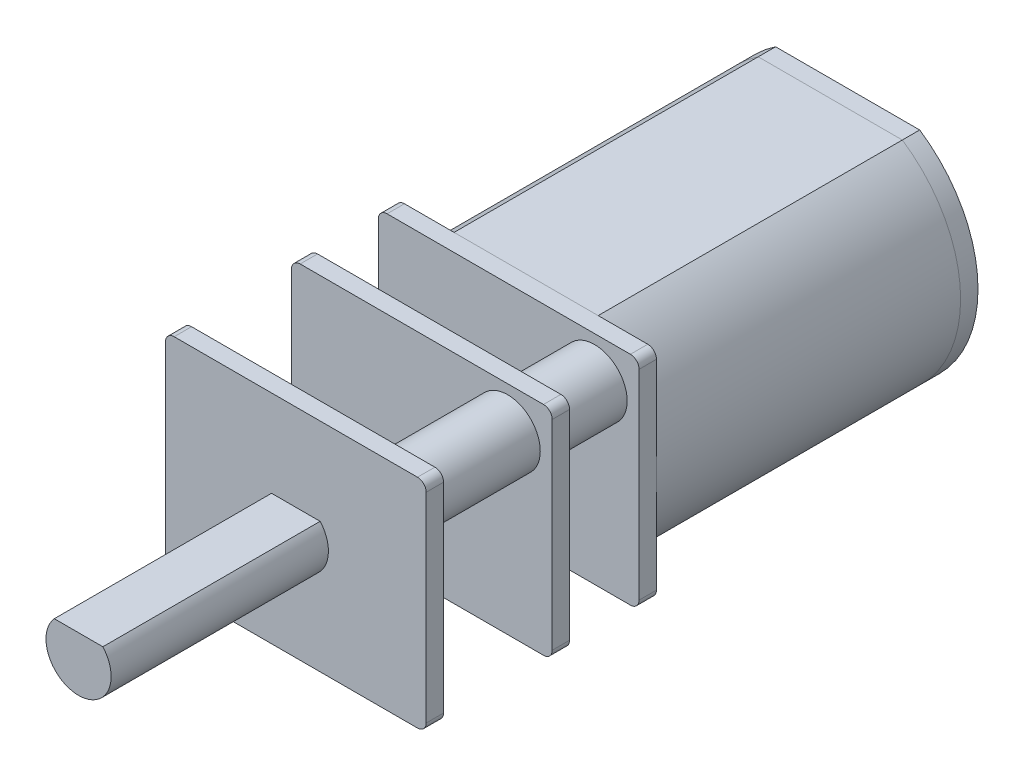
from build123d import *

# Parameters (mm, degrees)
EXTRUDE_1_DEPTH = 14
EXTRUDE_8_DEPTH = 0.8
SKETCH_2_R      = 2.5
EXTRUDE_2_DEPTH = 1.5
EXTRUDE_3_DEPTH = 0.8
EXTRUDE_START   = 3.2
EXTRUDE_4_DEPTH = 0.8
EXTRUDE_START_2 = 5
EXTRUDE_5_DEPTH = 0.8
SKETCH_6_R      = 1.5
EXTRUDE_6_DEPTH = 9.8
EXTRUDE_7_DEPTH = 10


with BuildPart() as part:
    # 草圖1 → 填料-伸長1 (new body)
    with BuildSketch(Plane.XY):
        with BuildLine():
            Line((-3.31662479, -5), (3.31662479, -5))
            ThreePointArc((3.31662479, -5), (6, 0), (3.31662479, 5))
            Line((3.31662479, 5), (-3.31662479, 5))
            ThreePointArc((-3.31662479, 5), (-6, 0), (-3.31662479, -5))
        make_face()
    extrude(amount=EXTRUDE_1_DEPTH)

    # 草圖2 → 填料-伸長2 (add)
    with BuildSketch(Plane(origin=(0, 0, 0), x_dir=(-1, 0, 0), z_dir=(0, 0, -1))):
        Circle(SKETCH_2_R)
    extrude(amount=EXTRUDE_2_DEPTH)


with BuildPart() as body_2:
    # 草圖8 → 填料-伸長8 (new body)
    with BuildSketch(Plane(origin=(0, 0, 0), x_dir=(-1, 0, 0), z_dir=(0, 0, -1))):
        with BuildLine():
            Line((-3.31662479, -5), (3.31662479, -5))
            ThreePointArc((3.31662479, -5), (6, 0), (3.31662479, 5))
            Line((3.31662479, 5), (-3.31662479, 5))
            ThreePointArc((-3.31662479, 5), (-6, 0), (-3.31662479, -5))
        make_face()
    extrude(amount=EXTRUDE_8_DEPTH)


with BuildPart() as body_3:
    # 草圖3 → 填料-伸長3 (new body)
    with BuildSketch(Plane.XY.offset(14)):
        with BuildLine():
            Line((-5.6, 5), (5.6, 5))
            ThreePointArc((5.6, 5), (5.882842712, 4.882842712), (6, 4.6))
            Line((6, 4.6), (6, -4.6))
            ThreePointArc((6, -4.6), (5.882842712, -4.882842712), (5.6, -5))
            Line((5.6, -5), (-5.6, -5))
            ThreePointArc((-5.6, -5), (-5.882842712, -4.882842712), (-6, -4.6))
            Line((-6, -4.6), (-6, 4.6))
            ThreePointArc((-6, 4.6), (-5.882842712, 4.882842712), (-5.6, 5))
        make_face()
    extrude(amount=EXTRUDE_3_DEPTH)



with BuildPart() as body_4:
    # 草圖4 → 填料-伸長4 (new body)
    with BuildSketch(Plane.XY.offset(14.8).offset(EXTRUDE_START)):
        with BuildLine():
            Line((-5.6, -5), (5.6, -5))
            ThreePointArc((5.6, -5), (5.882842712, -4.882842712), (6, -4.6))
            Line((6, -4.6), (6, 4.6))
            ThreePointArc((6, 4.6), (5.882842712, 4.882842712), (5.6, 5))
            Line((5.6, 5), (-5.6, 5))
            ThreePointArc((-5.6, 5), (-5.882842712, 4.882842712), (-6, 4.6))
            Line((-6, 4.6), (-6, -4.6))
            ThreePointArc((-6, -4.6), (-5.882842712, -4.882842712), (-5.6, -5))
        make_face()
    extrude(amount=EXTRUDE_4_DEPTH)


with BuildPart() as body_5:
    # 草圖5 → 填料-伸長5 (new body)
    with BuildSketch(Plane.XY.offset(18.8).offset(EXTRUDE_START_2)):
        with BuildLine():
            Line((-5.6, -5), (5.6, -5))
            ThreePointArc((5.6, -5), (5.882842712, -4.882842712), (6, -4.6))
            Line((6, -4.6), (6, 4.6))
            ThreePointArc((6, 4.6), (5.882842712, 4.882842712), (5.6, 5))
            Line((5.6, 5), (-5.6, 5))
            ThreePointArc((-5.6, 5), (-5.882842712, 4.882842712), (-6, 4.6))
            Line((-6, 4.6), (-6, -4.6))
            ThreePointArc((-6, -4.6), (-5.882842712, -4.882842712), (-5.6, -5))
        make_face()
    extrude(amount=EXTRUDE_5_DEPTH)


with BuildPart() as body_3_1:
    add(body_3.part)

    add(body_4.part)  # 填料-伸長6 merges body 4

    add(body_5.part)  # 填料-伸長6 merges body 5
    # 草圖6 → 填料-伸長6 (add)
    with BuildSketch(Plane.XY.offset(14.8)):
        with Locations((3.951189395, 3.064001038)):
            Circle(SKETCH_6_R)
        with Locations((-3.951189395, -3.064001038)):
            Circle(SKETCH_6_R)
    extrude(amount=EXTRUDE_6_DEPTH)


with BuildPart() as body_4_2:
    # 草圖7 → 填料-伸長7 (new body)
    with BuildSketch(Plane.XY.offset(24.6)):
        with BuildLine():
            Line((-1.118033989, 1), (1.118033989, 1))
            ThreePointArc((1.118033989, 1), (0, -1.5), (-1.118033989, 1))
        make_face()
    extrude(amount=EXTRUDE_7_DEPTH)


solid = Compound([part.part, body_2.part, body_3_1.part, body_4_2.part])
